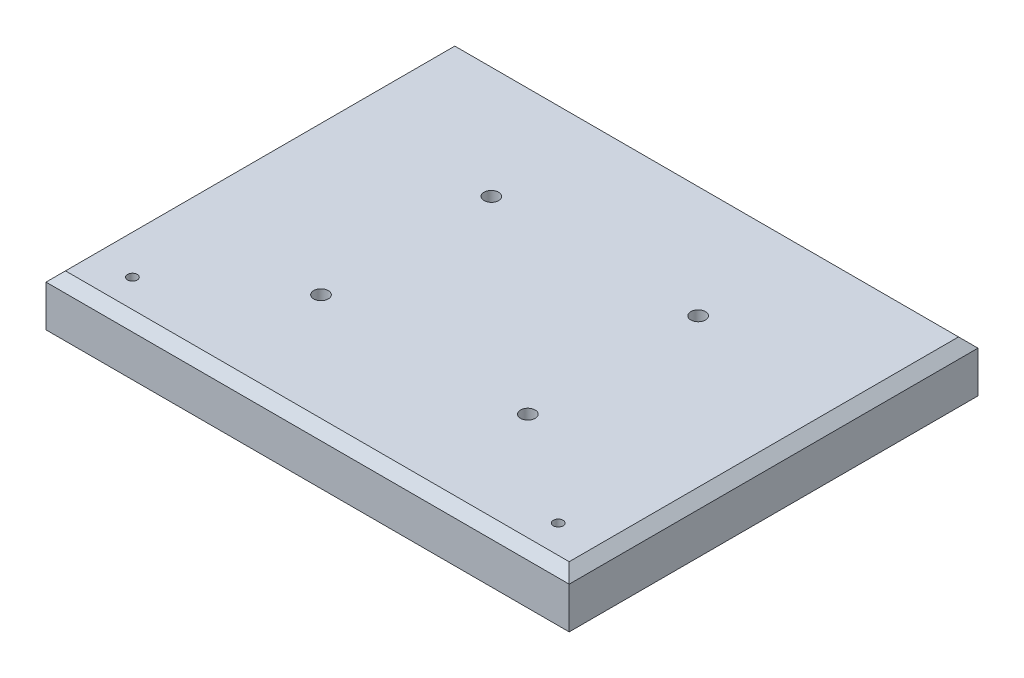
from build123d import *

# Parameters (mm, degrees)
SKETCH1_W           = 215
SKETCH1_H           = 168
SKETCH1_R           = 3
SKETCH1_R_2         = 2
BOSS_EXTRUDE1_DEPTH = 21
CHAMFER1_SIZE       = 4
SKETCH2_R           = 9.5
CUT_EXTRUDE1_DEPTH  = 13
SKETCH4_R           = 5
CUT_EXTRUDE2_DEPTH  = 6.5


with BuildPart() as part:
    # Sketch1 → Boss-Extrude1 (new body)
    with BuildSketch(Plane(origin=(0, 0, 0), x_dir=(1, 0, 0), z_dir=(0, 1, 0))):
        with Locations((107.5, 84)):
            Rectangle(SKETCH1_W, SKETCH1_H)
        with Locations((150, 118)):
            Circle(SKETCH1_R, mode=Mode.SUBTRACT)
        with Locations((65, 118)):
            Circle(SKETCH1_R, mode=Mode.SUBTRACT)
        with Locations((65, 48)):
            Circle(SKETCH1_R, mode=Mode.SUBTRACT)
        with Locations((150, 48)):
            Circle(SKETCH1_R, mode=Mode.SUBTRACT)
        with Locations((20, 15.5)):
            Circle(SKETCH1_R_2, mode=Mode.SUBTRACT)
        with Locations((195, 15.5)):
            Circle(SKETCH1_R_2, mode=Mode.SUBTRACT)
    extrude(amount=BOSS_EXTRUDE1_DEPTH)

    # Chamfer1
    chamfer1_edges = [part.edges().sort_by_distance(p)[0] for p in [
        (215, 21, -84),
        (107.5, 21, -168),
        (0, 21, -84),
        (107.5, 21, 0),
    ]]
    chamfer(chamfer1_edges, length=CHAMFER1_SIZE)

    # Sketch2 → Cut-Extrude1 (cut)
    with BuildSketch(Plane.XZ):
        with Locations((65, -48)):
            Circle(SKETCH2_R)
        with Locations((150, -48)):
            Circle(SKETCH2_R)
        with Locations((65, -118)):
            Circle(SKETCH2_R)
        with Locations((150, -118)):
            Circle(SKETCH2_R)
    extrude(amount=-CUT_EXTRUDE1_DEPTH, mode=Mode.SUBTRACT)

    # Sketch4 → Cut-Extrude2 (cut)
    with BuildSketch(Plane.XZ):
        with Locations((20, -15.5)):
            Circle(SKETCH4_R)
        with Locations((195, -15.5)):
            Circle(SKETCH4_R)
    extrude(amount=-CUT_EXTRUDE2_DEPTH, mode=Mode.SUBTRACT)


solid = part.part
